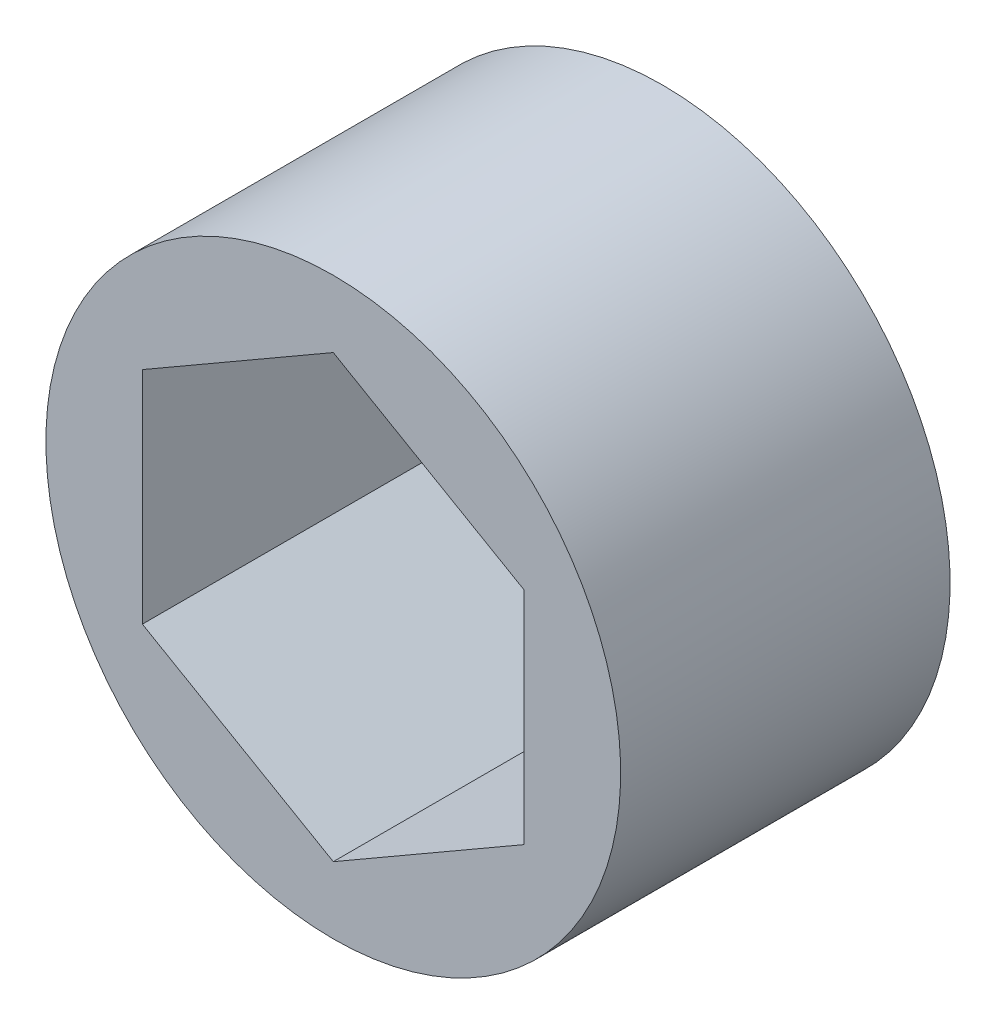
from build123d import *

# Parameters (mm, degrees)
SKETCH1_R           = 9.75
BOSS_EXTRUDE1_DEPTH = 11.176


with BuildPart() as part:
    # Sketch1 → Boss-Extrude1 (new body)
    with BuildSketch(Plane(origin=(0, 0, -1.5875), x_dir=(-1, 0, 0), z_dir=(0, 0, -1))):
        Circle(SKETCH1_R)
        Polygon((6.477, 3.739497694), (6.477, -3.739497694), (0, -7.478995387), (-6.477, -3.739497694), (-6.477, 3.739497694), (0, 7.478995387), align=None, mode=Mode.SUBTRACT)
    extrude(amount=-BOSS_EXTRUDE1_DEPTH)


solid = part.part
